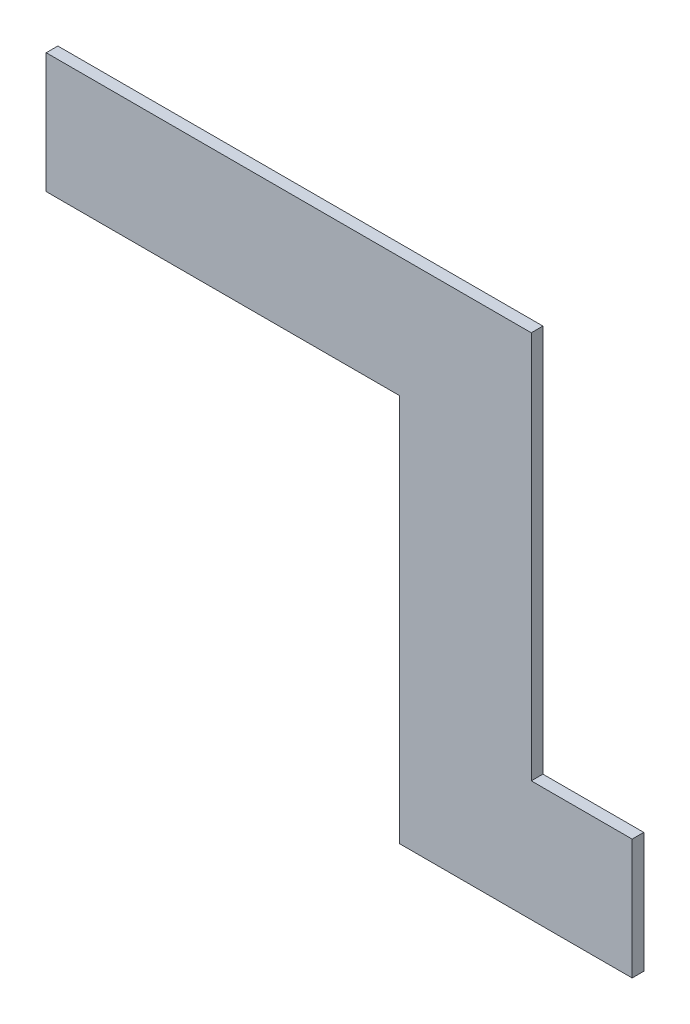
from build123d import *

# Parameters (mm, degrees)
BOSS_EXTRU_1_DEPTH = 3


with BuildPart() as part:
    # Esquisse1 → Boss.-Extru.1 (new body)
    with BuildSketch(Plane.XY):
        Polygon((-91, 81), (-91, 50), (0, 50), (0, -50), (60, -50), (60, -19), (34, -19), (34, 81), align=None)
    extrude(amount=BOSS_EXTRU_1_DEPTH)


solid = part.part
